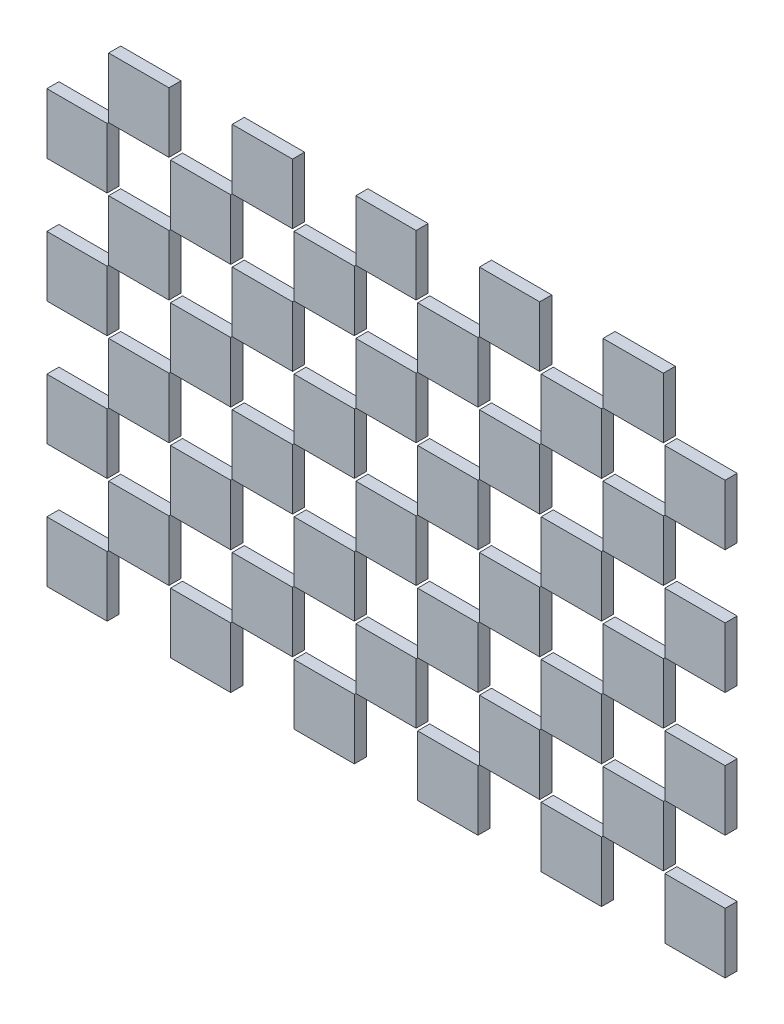
from build123d import *

# Parameters (mm, degrees)
SKETCH_1_W                  = 2
SKETCH_1_H                  = 2
EXTRUDE_1_DEPTH             = 0.4
PATTERN_LINEAR_1_COUNT      = 4
PATTERN_LINEAR_1_PITCH      = 4.1
PATTERN_LINEAR_1_2_COUNT    = 6
PATTERN_LINEAR_1_2_PITCH    = 4.1
SKETCH_2_W                  = 2
SKETCH_2_H                  = 2
EXTRUDE_2_DEPTH             = 0.4
PATTERN_LINEAR_2_COUNT      = 4
PATTERN_LINEAR_2_PITCH      = 4.1
PATTERN_LINEAR_2_COUNT_DIR2 = 5
PATTERN_LINEAR_2_PITCH_DIR2 = 4.1


with BuildPart() as part:
    # 草图1 → 凸台-拉伸1 (new body)
    with BuildSketch(Plane.XY):
        with Locations((-5.705263158, 7.115789474)):
            Rectangle(SKETCH_1_W, SKETCH_1_H)
    extrude(amount=EXTRUDE_1_DEPTH)


with BuildPart() as pattern_linear_1_1:
    # 阵列(线性)1: pattern copy
    add(part.part.moved(Location(Vector(0, 1, 0) * (1 * PATTERN_LINEAR_1_PITCH))))


with BuildPart() as pattern_linear_1_2:
    # 阵列(线性)1: pattern copy
    add(part.part.moved(Location(Vector(0, 1, 0) * (2 * PATTERN_LINEAR_1_PITCH))))


with BuildPart() as pattern_linear_1_3:
    # 阵列(线性)1: pattern copy
    add(part.part.moved(Location(Vector(0, 1, 0) * (3 * PATTERN_LINEAR_1_PITCH))))


with BuildPart() as pattern_linear_1_2_1:
    # Pattern Linear 1 2: pattern copy
    add(part.part.moved(Location(Vector(1, 0, 0) * (1 * PATTERN_LINEAR_1_2_PITCH))))


with BuildPart() as pattern_linear_1_2_2:
    # Pattern Linear 1 2: pattern copy
    add(part.part.moved(Location(Vector(1, 0, 0) * (2 * PATTERN_LINEAR_1_2_PITCH))))


with BuildPart() as pattern_linear_1_2_3:
    # Pattern Linear 1 2: pattern copy
    add(part.part.moved(Location(Vector(1, 0, 0) * (3 * PATTERN_LINEAR_1_2_PITCH))))


with BuildPart() as pattern_linear_1_2_4:
    # Pattern Linear 1 2: pattern copy
    add(part.part.moved(Location(Vector(1, 0, 0) * (4 * PATTERN_LINEAR_1_2_PITCH))))


with BuildPart() as pattern_linear_1_2_5:
    # Pattern Linear 1 2: pattern copy
    add(part.part.moved(Location(Vector(1, 0, 0) * (5 * PATTERN_LINEAR_1_2_PITCH))))


with BuildPart() as pattern_linear_1_2_6:
    # Pattern Linear 1 2: pattern copy
    add(pattern_linear_1_1.part.moved(Location(Vector(1, 0, 0) * (1 * PATTERN_LINEAR_1_2_PITCH))))


with BuildPart() as pattern_linear_1_2_7:
    # Pattern Linear 1 2: pattern copy
    add(pattern_linear_1_1.part.moved(Location(Vector(1, 0, 0) * (2 * PATTERN_LINEAR_1_2_PITCH))))


with BuildPart() as pattern_linear_1_2_8:
    # Pattern Linear 1 2: pattern copy
    add(pattern_linear_1_1.part.moved(Location(Vector(1, 0, 0) * (3 * PATTERN_LINEAR_1_2_PITCH))))


with BuildPart() as pattern_linear_1_2_9:
    # Pattern Linear 1 2: pattern copy
    add(pattern_linear_1_1.part.moved(Location(Vector(1, 0, 0) * (4 * PATTERN_LINEAR_1_2_PITCH))))


with BuildPart() as pattern_linear_1_2_10:
    # Pattern Linear 1 2: pattern copy
    add(pattern_linear_1_1.part.moved(Location(Vector(1, 0, 0) * (5 * PATTERN_LINEAR_1_2_PITCH))))


with BuildPart() as pattern_linear_1_2_11:
    # Pattern Linear 1 2: pattern copy
    add(pattern_linear_1_2.part.moved(Location(Vector(1, 0, 0) * (1 * PATTERN_LINEAR_1_2_PITCH))))


with BuildPart() as pattern_linear_1_2_12:
    # Pattern Linear 1 2: pattern copy
    add(pattern_linear_1_2.part.moved(Location(Vector(1, 0, 0) * (2 * PATTERN_LINEAR_1_2_PITCH))))


with BuildPart() as pattern_linear_1_2_13:
    # Pattern Linear 1 2: pattern copy
    add(pattern_linear_1_2.part.moved(Location(Vector(1, 0, 0) * (3 * PATTERN_LINEAR_1_2_PITCH))))


with BuildPart() as pattern_linear_1_2_14:
    # Pattern Linear 1 2: pattern copy
    add(pattern_linear_1_2.part.moved(Location(Vector(1, 0, 0) * (4 * PATTERN_LINEAR_1_2_PITCH))))


with BuildPart() as pattern_linear_1_2_15:
    # Pattern Linear 1 2: pattern copy
    add(pattern_linear_1_2.part.moved(Location(Vector(1, 0, 0) * (5 * PATTERN_LINEAR_1_2_PITCH))))


with BuildPart() as pattern_linear_1_2_16:
    # Pattern Linear 1 2: pattern copy
    add(pattern_linear_1_3.part.moved(Location(Vector(1, 0, 0) * (1 * PATTERN_LINEAR_1_2_PITCH))))


with BuildPart() as pattern_linear_1_2_17:
    # Pattern Linear 1 2: pattern copy
    add(pattern_linear_1_3.part.moved(Location(Vector(1, 0, 0) * (2 * PATTERN_LINEAR_1_2_PITCH))))


with BuildPart() as pattern_linear_1_2_18:
    # Pattern Linear 1 2: pattern copy
    add(pattern_linear_1_3.part.moved(Location(Vector(1, 0, 0) * (3 * PATTERN_LINEAR_1_2_PITCH))))


with BuildPart() as pattern_linear_1_2_19:
    # Pattern Linear 1 2: pattern copy
    add(pattern_linear_1_3.part.moved(Location(Vector(1, 0, 0) * (4 * PATTERN_LINEAR_1_2_PITCH))))


with BuildPart() as pattern_linear_1_2_20:
    # Pattern Linear 1 2: pattern copy
    add(pattern_linear_1_3.part.moved(Location(Vector(1, 0, 0) * (5 * PATTERN_LINEAR_1_2_PITCH))))


with BuildPart() as body_25:
    # 草图2 → 凸台-拉伸2 (new body)
    with BuildSketch(Plane.XY):
        with Locations((-3.655263158, 9.165789474)):
            Rectangle(SKETCH_2_W, SKETCH_2_H)
    extrude_2 = extrude(amount=EXTRUDE_2_DEPTH)


with BuildPart() as pattern_linear_2_1:
    # 阵列(线性)2: Extrude 2 4 × 5
    with Locations(*[(j * PATTERN_LINEAR_2_PITCH_DIR2, i * PATTERN_LINEAR_2_PITCH, 0) for i in range(PATTERN_LINEAR_2_COUNT) for j in range(PATTERN_LINEAR_2_COUNT_DIR2) if (i, j) != (0, 0)]):
        add(extrude_2)


solid = Compound([part.part, pattern_linear_1_1.part, pattern_linear_1_2.part, pattern_linear_1_3.part, pattern_linear_1_2_1.part, pattern_linear_1_2_2.part, pattern_linear_1_2_3.part, pattern_linear_1_2_4.part, pattern_linear_1_2_5.part, pattern_linear_1_2_6.part, pattern_linear_1_2_7.part, pattern_linear_1_2_8.part, pattern_linear_1_2_9.part, pattern_linear_1_2_10.part, pattern_linear_1_2_11.part, pattern_linear_1_2_12.part, pattern_linear_1_2_13.part, pattern_linear_1_2_14.part, pattern_linear_1_2_15.part, pattern_linear_1_2_16.part, pattern_linear_1_2_17.part, pattern_linear_1_2_18.part, pattern_linear_1_2_19.part, pattern_linear_1_2_20.part, body_25.part, pattern_linear_2_1.part])
